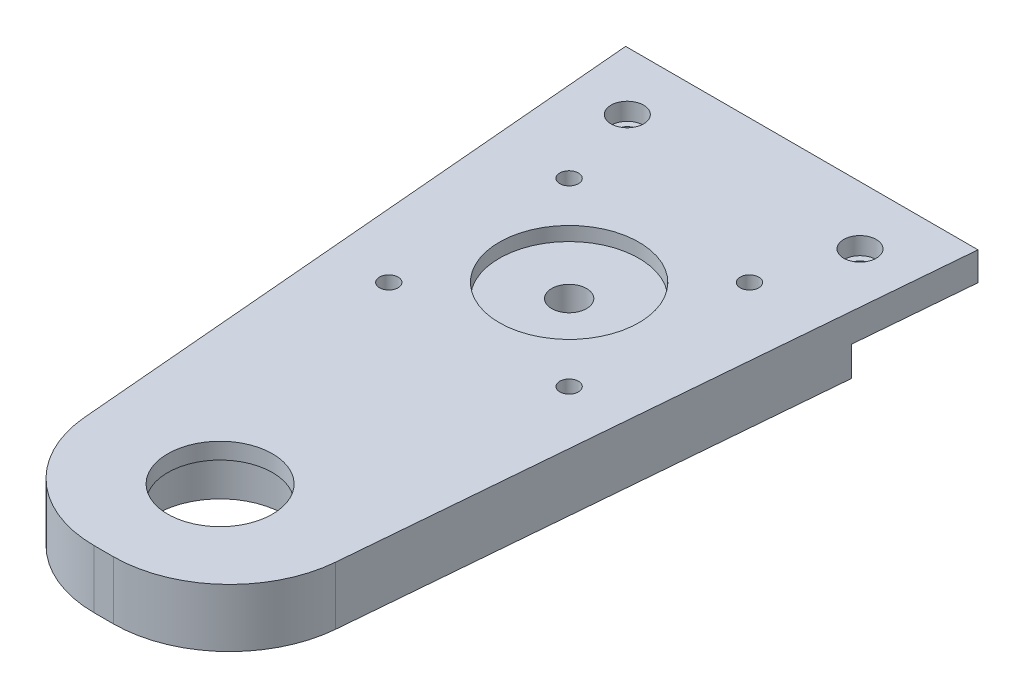
from build123d import *

# Parameters (mm, degrees)
SKETCH1_R           = 50
BOSS_EXTRUDE1_DEPTH = 10
SKETCH2_R           = 20
CUT_EXTRUDE1_DEPTH  = 5
CUT_EXTRUDE6_DEPTH  = 3
SKETCH8_R           = 1.7
CUT_EXTRUDE7_DEPTH  = 10
BOSS_EXTRUDE3_DEPTH = 10
CUT_EXTRUDE11_DEPTH = 10
SKETCH15_W          = 131.735170003
SKETCH15_H          = 179.266555965
CUT_EXTRUDE12_DEPTH = 79
BOSS_EXTRUDE4_DEPTH = 4.9
SKETCH17_R          = 1.7
CUT_EXTRUDE13_DEPTH = 10
CUT_EXTRUDE14_DEPTH = 3
SKETCH19_W          = 78.571428572
SKETCH19_H          = 5.1
CUT_EXTRUDE15_DEPTH = 0.5
SKETCH21_W          = 92.115977302
SKETCH21_H          = 140.887390287
CUT_EXTRUDE16_DEPTH = 10
CUT_EXTRUDE17_DEPTH = 5.1
SKETCH24_R          = 1.7
CUT_EXTRUDE19_DEPTH = 5.1
SKETCH25_R          = 11
CUT_EXTRUDE20_DEPTH = 7.2
SKETCH26_R          = 9
CUT_EXTRUDE21_DEPTH = 7.2
SKETCH27_R          = 3
CUT_EXTRUDE22_DEPTH = 11
SKETCH28_R          = 1.6
CUT_EXTRUDE23_DEPTH = 12
SKETCH29_R          = 2.9
SKETCH29_R_2        = 1.6
CUT_EXTRUDE24_DEPTH = 3.5
SKETCH30_R          = 12
CUT_EXTRUDE25_DEPTH = 2.4
SKETCH31_R          = 2.8
CUT_EXTRUDE26_DEPTH = 3
FILLET1_R           = 20


with BuildPart() as part:
    # Sketch1 → Boss-Extrude1 (new body)
    with BuildSketch(Plane(origin=(0, 0, 0), x_dir=(1, 0, 0), z_dir=(0, 1, 0))):
        Circle(SKETCH1_R)
    extrude(amount=BOSS_EXTRUDE1_DEPTH)

    # Sketch2 → Cut-Extrude1 (cut)
    with BuildSketch(Plane(origin=(0, 10, 0), x_dir=(1, 0, 0), z_dir=(0, 1, 0))):
        Circle(SKETCH2_R)
    extrude(amount=-CUT_EXTRUDE1_DEPTH, mode=Mode.SUBTRACT)

    # Sketch7 → Cut-Extrude6 (cut)
    with BuildSketch(Plane.XZ):
        Polygon((12.990381057, -4.209103466), (10.140381057, -5.854551733), (10.140381057, -9.145448267), (12.990381057, -10.790896534), (15.840381057, -9.145448267), (15.840381057, -5.854551733), align=None)
        Polygon((-12.990381057, -4.209103466), (-15.840381057, -5.854551733), (-15.840381057, -9.145448267), (-12.990381057, -10.790896534), (-10.140381057, -9.145448267), (-10.140381057, -5.854551733), align=None)
        Polygon((-2.85, 16.645448267), (-2.85, 13.354551733), (0, 11.709103466), (2.85, 13.354551733), (2.85, 16.645448267), (0, 18.290896534), align=None)
    extrude(amount=-CUT_EXTRUDE6_DEPTH, mode=Mode.SUBTRACT)

    # Sketch8 → Cut-Extrude7 (cut)
    with BuildSketch(Plane.XZ):
        with Locations((0, 15)):
            Circle(SKETCH8_R)
        with Locations((12.990381057, -7.5)):
            Circle(SKETCH8_R)
        with Locations((-12.990381057, -7.5)):
            Circle(SKETCH8_R)
    extrude(amount=-CUT_EXTRUDE7_DEPTH, mode=Mode.SUBTRACT)


with BuildPart() as body_2:
    # Sketch9 → Boss-Extrude3 (new body)
    with BuildSketch(Plane.XZ):
        with BuildLine():
            Line((-50, 350), (-50, 0))
            ThreePointArc((-50, 0), (0, 50), (50, 0))
            Line((50, 0), (50, 350))
            Line((50, 350), (-50, 350))
        make_face()
    extrude(amount=-BOSS_EXTRUDE3_DEPTH)

    # Sketch13 → Cut-Extrude11 (cut)
    with BuildSketch(Plane.XZ):
        with BuildLine():
            Line((-50, 350), (-50, 0))
            ThreePointArc((-50, 0), (-49.817332452, 4.270057067), (-49.270664506, 8.5089141))
            Line((-49.270664506, 8.5089141), (-20, 350))
            Line((-20, 350), (-50, 350))
        make_face()
        with BuildLine():
            Line((20, 350), (49.270664506, 8.5089141))
            ThreePointArc((49.270664506, 8.5089141), (49.817332452, 4.270057067), (50, 0))
            Line((50, 0), (50, 350))
            Line((50, 350), (20, 350))
        make_face()
    extrude(amount=-CUT_EXTRUDE11_DEPTH, mode=Mode.SUBTRACT)


with BuildPart() as cut_extrude12_tool:
    # Sketch15 → Cut-Extrude12 (new body)
    with BuildSketch(Plane(origin=(0, 10, 0), x_dir=(1, 0, 0), z_dir=(0, 1, 0))):
        with Locations((-8.166136658, -35.366722018)):
            Rectangle(SKETCH15_W, SKETCH15_H)
    extrude(amount=-CUT_EXTRUDE12_DEPTH)


with BuildPart() as part_1:
    add(part.part)

    # Cut-Extrude12: cut by cut_extrude12_tool
    add(cut_extrude12_tool.part, mode=Mode.SUBTRACT)


with BuildPart() as body_2_1:
    add(body_2.part)

    # Cut-Extrude12: cut by cut_extrude12_tool
    add(cut_extrude12_tool.part, mode=Mode.SUBTRACT)

    # Sketch16 → Boss-Extrude4 (add)
    with BuildSketch(Plane(origin=(0, 10, 0), x_dir=(1, 0, 0), z_dir=(0, 1, 0))):
        Polygon((40.972386827, -105.322153681), (-40.972386827, -105.322153681), (-39.285714286, -125), (39.285714286, -125), align=None)
    extrude(amount=-BOSS_EXTRUDE4_DEPTH)

    # Sketch17 → Cut-Extrude13 (cut)
    with BuildSketch(Plane.XZ.offset(-5.1)):
        with Locations((-25, 115)):
            Circle(SKETCH17_R)
        with Locations((25, 115)):
            Circle(SKETCH17_R)
    extrude(amount=-CUT_EXTRUDE13_DEPTH, mode=Mode.SUBTRACT)

    # Sketch18 → Cut-Extrude14 (cut)
    with BuildSketch(Plane(origin=(0, 10, 0), x_dir=(1, 0, 0), z_dir=(0, 1, 0))):
        Polygon((-25, -111.651368439), (-27.9, -113.325684219), (-27.9, -116.674315781), (-25, -118.348631561), (-22.1, -116.674315781), (-22.1, -113.325684219), align=None)
        Polygon((22.1, -113.325684219), (25, -111.651368439), (27.9, -113.325684219), (27.9, -116.674315781), (25, -118.348631561), (22.1, -116.674315781), align=None)
    extrude(amount=-CUT_EXTRUDE14_DEPTH, mode=Mode.SUBTRACT)

    # Sketch19 → Cut-Extrude15 (cut)
    with BuildSketch(Plane(origin=(0, 0, 125), x_dir=(-1, 0, 0), z_dir=(0, 0, -1))):
        with Locations((0, 2.55)):
            Rectangle(SKETCH19_W, SKETCH19_H)
    extrude(amount=-CUT_EXTRUDE15_DEPTH, mode=Mode.SUBTRACT)

    # Sketch21 → Cut-Extrude16 (cut)
    with BuildSketch(Plane.XZ):
        with Locations((0.437891513, 159.556304857)):
            Rectangle(SKETCH21_W, SKETCH21_H)
    extrude(amount=-CUT_EXTRUDE16_DEPTH, mode=Mode.SUBTRACT)

    # Sketch21_3 → Cut-Extrude17 (cut)
    with BuildSketch(Plane.XZ):
        Polygon((-28.571428571, 250), (-30.285714286, 230), (30.285714286, 230), (28.571428571, 250), align=None)
    extrude(amount=-CUT_EXTRUDE17_DEPTH, mode=Mode.SUBTRACT)

    # Sketch24 → Cut-Extrude19 (cut)
    with BuildSketch(Plane.XZ.offset(-5.1)):
        with Locations((20, 240)):
            Circle(SKETCH24_R)
        with Locations((-20, 240)):
            Circle(SKETCH24_R)
    extrude(amount=-CUT_EXTRUDE19_DEPTH, mode=Mode.SUBTRACT)

    # Sketch25 → Cut-Extrude20 (cut)
    with BuildSketch(Plane.XZ):
        with Locations((0, 330)):
            Circle(SKETCH25_R)
    extrude(amount=-CUT_EXTRUDE20_DEPTH, mode=Mode.SUBTRACT)

    # Sketch26 → Cut-Extrude21 (cut)
    with BuildSketch(Plane.XZ.offset(-7.2)):
        with Locations((0, 330)):
            Circle(SKETCH26_R)
    extrude(amount=-CUT_EXTRUDE21_DEPTH, mode=Mode.SUBTRACT)

    # Sketch27 → Cut-Extrude22 (cut)
    with BuildSketch(Plane.XZ):
        with Locations((0, 270)):
            Circle(SKETCH27_R)
    extrude(amount=-CUT_EXTRUDE22_DEPTH, mode=Mode.SUBTRACT)

    # Sketch28 → Cut-Extrude23 (cut)
    with BuildSketch(Plane(origin=(0, 10, 0), x_dir=(1, 0, 0), z_dir=(0, 1, 0))):
        with Locations((-15.5, -254.5)):
            Circle(SKETCH28_R)
        with Locations((15.5, -254.5)):
            Circle(SKETCH28_R)
        with Locations((15.5, -285.5)):
            Circle(SKETCH28_R)
        with Locations((-15.5, -285.5)):
            Circle(SKETCH28_R)
    extrude(amount=-CUT_EXTRUDE23_DEPTH, mode=Mode.SUBTRACT)

    # Sketch29 → Cut-Extrude24 (cut)
    # profile 1 of 4: a face of its own
    with BuildSketch(Plane.XZ):
        with Locations((-15.5, 285.5)):
            Circle(SKETCH29_R)
        with Locations((-15.5, 285.5)):
            Circle(SKETCH29_R_2, mode=Mode.SUBTRACT)
    # profile 2 of 4: a face of its own
    with BuildSketch(Plane.XZ):
        with Locations((15.5, 285.5)):
            Circle(SKETCH29_R)
    # profile 3 of 4: a face of its own
    with BuildSketch(Plane.XZ):
        with Locations((15.5, 254.5)):
            Circle(SKETCH29_R)
    # profile 4 of 4: a face of its own
    with BuildSketch(Plane.XZ):
        with Locations((-15.5, 254.5)):
            Circle(SKETCH29_R)
    extrude(amount=-CUT_EXTRUDE24_DEPTH, mode=Mode.SUBTRACT)

    # Sketch30 → Cut-Extrude25 (cut)
    with BuildSketch(Plane(origin=(0, 10, 0), x_dir=(1, 0, 0), z_dir=(0, 1, 0))):
        with Locations((0, -270)):
            Circle(SKETCH30_R)
    extrude(amount=-CUT_EXTRUDE25_DEPTH, mode=Mode.SUBTRACT)

    # Sketch31 → Cut-Extrude26 (cut)
    with BuildSketch(Plane(origin=(0, 10, 0), x_dir=(1, 0, 0), z_dir=(0, 1, 0))):
        with Locations((-20, -240)):
            Circle(SKETCH31_R)
        with Locations((20, -240)):
            Circle(SKETCH31_R)
    extrude(amount=-CUT_EXTRUDE26_DEPTH, mode=Mode.SUBTRACT)

    # Fillet1
    fillet1_edges = [body_2_1.edges().sort_by_distance(p)[0] for p in [
        (-20, 5, 350),
        (20, 5, 350),
    ]]
    fillet(fillet1_edges, radius=FILLET1_R)


solid = body_2_1.part
